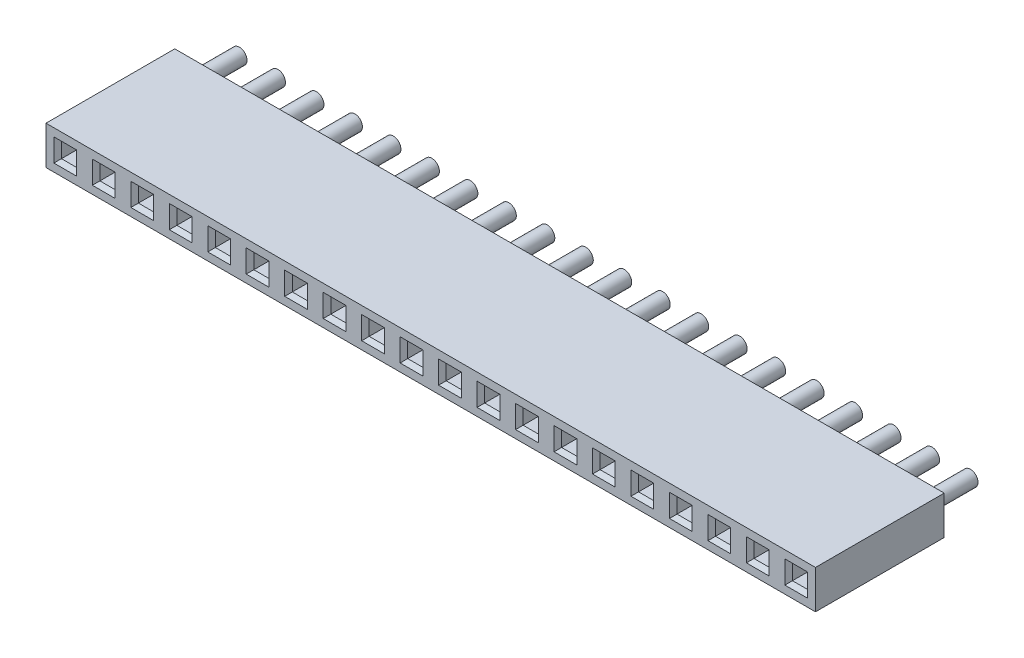
from build123d import *

# Parameters (mm, degrees)
SKETCH1_W                  = 2.54
SKETCH1_H                  = 2.54
BOSS_EXTRUDE1_DEPTH        = 8.5
SKETCH2_W                  = 1
SKETCH2_H                  = 1
CUT_EXTRUDE1_DEPTH         = 8
CHAMFER1_SIZE              = 0.25
SKETCH3_R                  = 0.5
BOSS_EXTRUDE2_DEPTH        = 3
LPATTERN3_COUNT            = 20
LPATTERN3_PITCH            = 2.54
CHAMFER1_OF_LPATTERN3_SIZE = 0.25


with BuildPart() as part:
    # Sketch1 → Boss-Extrude1 (new body)
    with BuildSketch(Plane.XY):
        with Locations((1.27, 1.27)):
            Rectangle(SKETCH1_W, SKETCH1_H)
    boss_extrude1 = extrude(amount=BOSS_EXTRUDE1_DEPTH)

    # Sketch2 → Cut-Extrude1 (cut)
    with BuildSketch(Plane.XY.offset(8.5)):
        with Locations((1.27, 1.27)):
            Rectangle(SKETCH2_W, SKETCH2_H)
    cut_extrude1 = extrude(amount=-CUT_EXTRUDE1_DEPTH, mode=Mode.SUBTRACT)

    # Chamfer1
    chamfer1_edges = [part.edges().sort_by_distance(p)[0] for p in [
        (0.77, 1.27, 8.5),
        (1.27, 0.77, 8.5),
        (1.77, 1.27, 8.5),
        (1.27, 1.77, 8.5),
    ]]
    chamfer(chamfer1_edges, length=CHAMFER1_SIZE)

    # Sketch3 → Boss-Extrude2 (add)
    with BuildSketch(Plane(origin=(0, 0, 0), x_dir=(-1, 0, 0), z_dir=(0, 0, -1))):
        with Locations((-1.27, 1.27)):
            Circle(SKETCH3_R)
    boss_extrude2 = extrude(amount=BOSS_EXTRUDE2_DEPTH)

    # LPattern3: Boss-Extrude1, Cut-Extrude1, Boss-Extrude2 ×20
    with Locations(*[(i * LPATTERN3_PITCH, 0, 0) for i in range(1, LPATTERN3_COUNT)]):
        add(boss_extrude1)
        add(cut_extrude1, mode=Mode.SUBTRACT)
        add(boss_extrude2)

    # Chamfer1 of LPattern3
    chamfer1_of_lpattern3_edges = [part.edges().sort_by_distance(p)[0] for p in [
        (3.31, 1.27, 8.5),
        (3.81, 0.77, 8.5),
        (4.31, 1.27, 8.5),
        (3.81, 1.77, 8.5),
        (5.85, 1.27, 8.5),
        (6.35, 0.77, 8.5),
        (6.85, 1.27, 8.5),
        (6.35, 1.77, 8.5),
        (8.39, 1.27, 8.5),
        (8.89, 0.77, 8.5),
        (9.39, 1.27, 8.5),
        (8.89, 1.77, 8.5),
        (10.93, 1.27, 8.5),
        (11.43, 0.77, 8.5),
        (11.93, 1.27, 8.5),
        (11.43, 1.77, 8.5),
        (13.47, 1.27, 8.5),
        (13.97, 0.77, 8.5),
        (14.47, 1.27, 8.5),
        (13.97, 1.77, 8.5),
        (16.01, 1.27, 8.5),
        (16.51, 0.77, 8.5),
        (17.01, 1.27, 8.5),
        (16.51, 1.77, 8.5),
        (18.55, 1.27, 8.5),
        (19.05, 0.77, 8.5),
        (19.55, 1.27, 8.5),
        (19.05, 1.77, 8.5),
        (21.09, 1.27, 8.5),
        (21.59, 0.77, 8.5),
        (22.09, 1.27, 8.5),
        (21.59, 1.77, 8.5),
        (23.63, 1.27, 8.5),
        (24.13, 0.77, 8.5),
        (24.63, 1.27, 8.5),
        (24.13, 1.77, 8.5),
        (26.17, 1.27, 8.5),
        (26.67, 0.77, 8.5),
        (27.17, 1.27, 8.5),
        (26.67, 1.77, 8.5),
        (28.71, 1.27, 8.5),
        (29.21, 0.77, 8.5),
        (29.71, 1.27, 8.5),
        (29.21, 1.77, 8.5),
        (31.25, 1.27, 8.5),
        (31.75, 0.77, 8.5),
        (32.25, 1.27, 8.5),
        (31.75, 1.77, 8.5),
        (33.79, 1.27, 8.5),
        (34.29, 0.77, 8.5),
        (34.79, 1.27, 8.5),
        (34.29, 1.77, 8.5),
        (36.33, 1.27, 8.5),
        (36.83, 0.77, 8.5),
        (37.33, 1.27, 8.5),
        (36.83, 1.77, 8.5),
        (38.87, 1.27, 8.5),
        (39.37, 0.77, 8.5),
        (39.87, 1.27, 8.5),
        (39.37, 1.77, 8.5),
        (41.41, 1.27, 8.5),
        (41.91, 0.77, 8.5),
        (42.41, 1.27, 8.5),
        (41.91, 1.77, 8.5),
        (43.95, 1.27, 8.5),
        (44.45, 0.77, 8.5),
        (44.95, 1.27, 8.5),
        (44.45, 1.77, 8.5),
        (46.49, 1.27, 8.5),
        (46.99, 0.77, 8.5),
        (47.49, 1.27, 8.5),
        (46.99, 1.77, 8.5),
        (49.03, 1.27, 8.5),
        (49.53, 0.77, 8.5),
        (50.03, 1.27, 8.5),
        (49.53, 1.77, 8.5),
    ]]
    chamfer(chamfer1_of_lpattern3_edges, length=CHAMFER1_OF_LPATTERN3_SIZE)


solid = part.part
